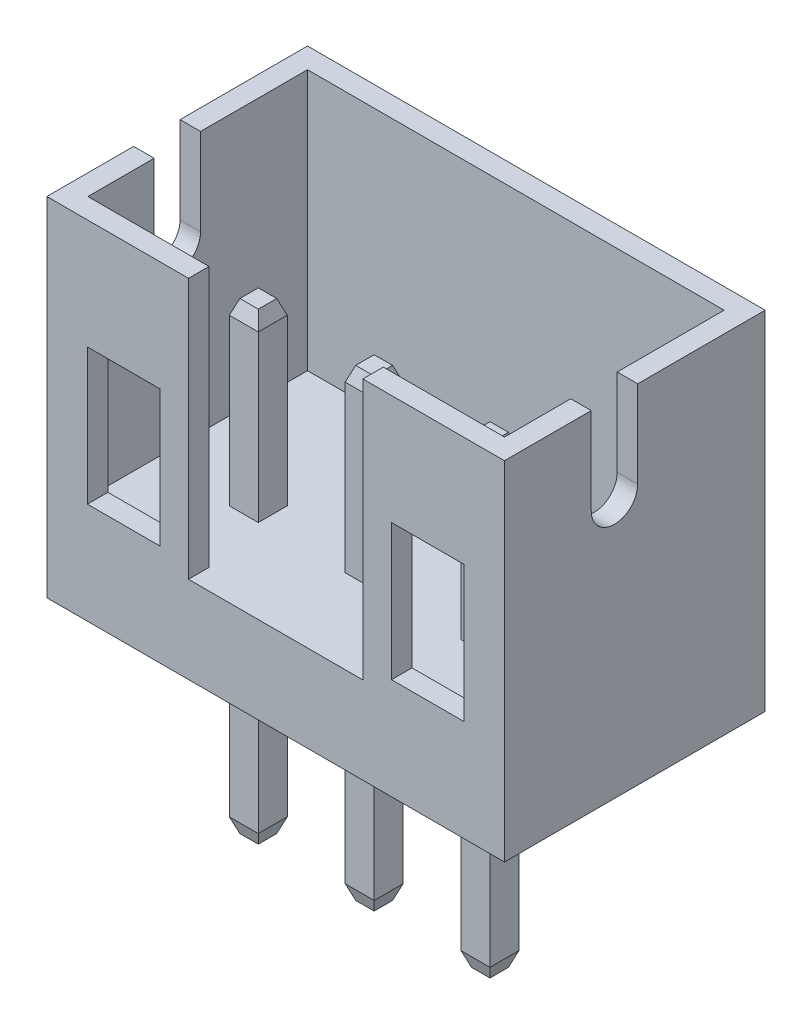
from build123d import *

# Parameters (mm, degrees)
SKETCH1_W              = 7.9
SKETCH1_H              = 6
BOSS_EXTRUDE1_DEPTH    = 4.5
SKETCH2_W              = 7.192186002
SKETCH2_H              = 3.792186002
CUT_EXTRUDE1_DEPTH     = 4.5
SKETCH3_W              = 1.504949596
SKETCH3_H              = 0.354260607
CUT_EXTRUDE2_DEPTH     = 4.5
CUT_EXTRUDE3_DEPTH     = 0.5
SKETCH6_W              = 1.25
SKETCH6_H              = 2.35
CUT_EXTRUDE4_DEPTH     = 0.5
BOSS_EXTRUDE3_START    = -3.4
SKETCH10_W             = 0.5
SKETCH10_H             = 0.5
BOSS_EXTRUDE3_DEPTH    = 8
CHAMFER1_SIZE          = 0.25
CHAMFER1_SIZE2         = 0.090992559
CHAMFER1_PART_2_SIZE   = 0.25
CHAMFER1_PART_2_SIZE2  = 0.090992559
CHAMFER1_PART_3_SIZE   = 0.25
CHAMFER1_PART_3_SIZE2  = 0.090992559
CHAMFER1_PART_4_SIZE   = 0.25
CHAMFER1_PART_4_SIZE2  = 0.090992559
CHAMFER1_PART_5_SIZE   = 0.25
CHAMFER1_PART_5_SIZE2  = 0.090992559
CHAMFER1_PART_6_SIZE   = 0.25
CHAMFER1_PART_6_SIZE2  = 0.090992559
CHAMFER1_PART_7_SIZE   = 0.25
CHAMFER1_PART_7_SIZE2  = 0.090992559
CHAMFER1_PART_8_SIZE   = 0.25
CHAMFER1_PART_8_SIZE2  = 0.090992559
CHAMFER1_PART_9_SIZE   = 0.25
CHAMFER1_PART_9_SIZE2  = 0.090992559
CHAMFER1_PART_10_SIZE  = 0.25
CHAMFER1_PART_10_SIZE2 = 0.090992559
CHAMFER1_PART_11_SIZE  = 0.25
CHAMFER1_PART_11_SIZE2 = 0.090992559
CHAMFER1_PART_12_SIZE  = 0.25
CHAMFER1_PART_12_SIZE2 = 0.090992559
CHAMFER2_SIZE          = 0.25
CHAMFER2_SIZE2         = 0.090992559
CHAMFER2_PART_2_SIZE   = 0.25
CHAMFER2_PART_2_SIZE2  = 0.090992559
CHAMFER2_PART_3_SIZE   = 0.25
CHAMFER2_PART_3_SIZE2  = 0.090992559
CHAMFER2_PART_4_SIZE   = 0.25
CHAMFER2_PART_4_SIZE2  = 0.090992559
CHAMFER2_PART_5_SIZE   = 0.25
CHAMFER2_PART_5_SIZE2  = 0.090992559
CHAMFER2_PART_6_SIZE   = 0.25
CHAMFER2_PART_6_SIZE2  = 0.090992559
CHAMFER2_PART_7_SIZE   = 0.25
CHAMFER2_PART_7_SIZE2  = 0.090992559
CHAMFER2_PART_8_SIZE   = 0.25
CHAMFER2_PART_8_SIZE2  = 0.090992559
CHAMFER2_PART_9_SIZE   = 0.25
CHAMFER2_PART_9_SIZE2  = 0.090992559
CHAMFER2_PART_10_SIZE  = 0.25
CHAMFER2_PART_10_SIZE2 = 0.090992559
CHAMFER2_PART_11_SIZE  = 0.25
CHAMFER2_PART_11_SIZE2 = 0.090992559
CHAMFER2_PART_12_SIZE  = 0.25
CHAMFER2_PART_12_SIZE2 = 0.090992559


with BuildPart() as part:
    # Sketch1 → Boss-Extrude1 (new body)
    with BuildSketch(Plane.XY):
        with Locations((3.95, 3)):
            Rectangle(SKETCH1_W, SKETCH1_H)
    extrude(amount=-BOSS_EXTRUDE1_DEPTH)

    # Sketch2 → Cut-Extrude1 (cut)
    with BuildSketch(Plane(origin=(0, 6, 0), x_dir=(1, 0, 0), z_dir=(0, 1, 0))):
        with Locations((3.950353608, 2.249646392)):
            Rectangle(SKETCH2_W, SKETCH2_H)
    extrude(amount=-CUT_EXTRUDE1_DEPTH, mode=Mode.SUBTRACT)

    # Sketch3 → Cut-Extrude2 (cut)
    with BuildSketch(Plane(origin=(0, 1.5, 0), x_dir=(1, 0, 0), z_dir=(0, 1, 0))):
        with Locations((3.197525202, 0.177130304)):
            Rectangle(SKETCH3_W, SKETCH3_H)
    cut_extrude2 = extrude(amount=CUT_EXTRUDE2_DEPTH, mode=Mode.SUBTRACT)

    # Sketch5 → Cut-Extrude3 (cut)
    with BuildSketch(Plane(origin=(7.9, 0, 0), x_dir=(0, 0, -1), z_dir=(1, 0, 0))):
        with BuildLine():
            Line((2.299478677, 6), (1.497924103, 6))
            Line((1.497924103, 6), (1.497924103, 4.5))
            ThreePointArc((1.497924103, 4.5), (1.89870139, 4.900777287), (2.299478677, 4.5))
            Line((2.299478677, 4.5), (2.299478677, 6))
        make_face()
        with BuildLine():
            ThreePointArc((2.299478677, 4.5), (1.89870139, 4.900777287), (1.497924103, 4.5))
            Line((1.497924103, 4.5), (2.299478677, 4.5))
        make_face()
        with BuildLine():
            Line((2.299478677, 4.5), (1.497924103, 4.5))
            ThreePointArc((1.497924103, 4.5), (1.89870139, 4.099222713), (2.299478677, 4.5))
        make_face()
    cut_extrude3 = extrude(amount=-CUT_EXTRUDE3_DEPTH, mode=Mode.SUBTRACT)

    # Mirror1: Cut-Extrude3 across plane
    add(cut_extrude3.mirror(Plane(origin=(3.95, 0, 0), x_dir=(0, 0, 1), z_dir=(1, 0, 0))), mode=Mode.SUBTRACT)

    # Sketch6 → Cut-Extrude4 (cut)
    with BuildSketch(Plane.XY):
        with Locations((1.325196701, 2.925654718)):
            Rectangle(SKETCH6_W, SKETCH6_H)
    cut_extrude4 = extrude(amount=-CUT_EXTRUDE4_DEPTH, mode=Mode.SUBTRACT)

    # Sketch10 → Boss-Extrude3 (add)
    with BuildSketch(Plane(origin=(0, 0, 0), x_dir=(1, 0, 0), z_dir=(0, 1, 0)).offset(BOSS_EXTRUDE3_START)):
        with Locations((1.95, 1.7)):
            Rectangle(SKETCH10_W, SKETCH10_H)
        with Locations((3.95, 1.7)):
            Rectangle(SKETCH10_W, SKETCH10_H)
        with Locations((5.95, 1.7)):
            Rectangle(SKETCH10_W, SKETCH10_H)
    extrude(amount=BOSS_EXTRUDE3_DEPTH)

    # Chamfer1
    chamfer1_edges = [part.edges().sort_by_distance(p)[0] for p in [
        (2.2, 4.6, -1.7),
    ]]
    chamfer1_side = [part.faces().sort_by_distance(p)[0] for p in [
        (2.2, 3.05, -1.7),
    ]]
    chamfer(chamfer1_edges, length=CHAMFER1_SIZE, length2=CHAMFER1_SIZE2, reference=chamfer1_side[0])

    # Chamfer1 part 2
    chamfer1_part_2_edges = [part.edges().sort_by_distance(p)[0] for p in [
        (1.95, 4.6, -1.95),
    ]]
    chamfer1_part_2_side = [part.faces().sort_by_distance(p)[0] for p in [
        (1.95, 3.05, -1.95),
    ]]
    chamfer(chamfer1_part_2_edges, length=CHAMFER1_PART_2_SIZE, length2=CHAMFER1_PART_2_SIZE2, reference=chamfer1_part_2_side[0])

    # Chamfer1 part 3
    chamfer1_part_3_edges = [part.edges().sort_by_distance(p)[0] for p in [
        (1.7, 4.6, -1.7),
    ]]
    chamfer1_part_3_side = [part.faces().sort_by_distance(p)[0] for p in [
        (1.7, 3.05, -1.7),
    ]]
    chamfer(chamfer1_part_3_edges, length=CHAMFER1_PART_3_SIZE, length2=CHAMFER1_PART_3_SIZE2, reference=chamfer1_part_3_side[0])

    # Chamfer1 part 4
    chamfer1_part_4_edges = [part.edges().sort_by_distance(p)[0] for p in [
        (1.95, 4.6, -1.45),
    ]]
    chamfer1_part_4_side = [part.faces().sort_by_distance(p)[0] for p in [
        (1.95, 3.05, -1.45),
    ]]
    chamfer(chamfer1_part_4_edges, length=CHAMFER1_PART_4_SIZE, length2=CHAMFER1_PART_4_SIZE2, reference=chamfer1_part_4_side[0])

    # Chamfer1 part 5
    chamfer1_part_5_edges = [part.edges().sort_by_distance(p)[0] for p in [
        (4.2, 4.6, -1.7),
    ]]
    chamfer1_part_5_side = [part.faces().sort_by_distance(p)[0] for p in [
        (4.2, 3.05, -1.7),
    ]]
    chamfer(chamfer1_part_5_edges, length=CHAMFER1_PART_5_SIZE, length2=CHAMFER1_PART_5_SIZE2, reference=chamfer1_part_5_side[0])

    # Chamfer1 part 6
    chamfer1_part_6_edges = [part.edges().sort_by_distance(p)[0] for p in [
        (3.95, 4.6, -1.95),
    ]]
    chamfer1_part_6_side = [part.faces().sort_by_distance(p)[0] for p in [
        (3.95, 3.05, -1.95),
    ]]
    chamfer(chamfer1_part_6_edges, length=CHAMFER1_PART_6_SIZE, length2=CHAMFER1_PART_6_SIZE2, reference=chamfer1_part_6_side[0])

    # Chamfer1 part 7
    chamfer1_part_7_edges = [part.edges().sort_by_distance(p)[0] for p in [
        (3.7, 4.6, -1.7),
    ]]
    chamfer1_part_7_side = [part.faces().sort_by_distance(p)[0] for p in [
        (3.7, 3.05, -1.7),
    ]]
    chamfer(chamfer1_part_7_edges, length=CHAMFER1_PART_7_SIZE, length2=CHAMFER1_PART_7_SIZE2, reference=chamfer1_part_7_side[0])

    # Chamfer1 part 8
    chamfer1_part_8_edges = [part.edges().sort_by_distance(p)[0] for p in [
        (3.95, 4.6, -1.45),
    ]]
    chamfer1_part_8_side = [part.faces().sort_by_distance(p)[0] for p in [
        (3.95, 3.05, -1.45),
    ]]
    chamfer(chamfer1_part_8_edges, length=CHAMFER1_PART_8_SIZE, length2=CHAMFER1_PART_8_SIZE2, reference=chamfer1_part_8_side[0])

    # Chamfer1 part 9
    chamfer1_part_9_edges = [part.edges().sort_by_distance(p)[0] for p in [
        (6.2, 4.6, -1.7),
    ]]
    chamfer1_part_9_side = [part.faces().sort_by_distance(p)[0] for p in [
        (6.2, 3.05, -1.7),
    ]]
    chamfer(chamfer1_part_9_edges, length=CHAMFER1_PART_9_SIZE, length2=CHAMFER1_PART_9_SIZE2, reference=chamfer1_part_9_side[0])

    # Chamfer1 part 10
    chamfer1_part_10_edges = [part.edges().sort_by_distance(p)[0] for p in [
        (5.95, 4.6, -1.95),
    ]]
    chamfer1_part_10_side = [part.faces().sort_by_distance(p)[0] for p in [
        (5.95, 3.05, -1.95),
    ]]
    chamfer(chamfer1_part_10_edges, length=CHAMFER1_PART_10_SIZE, length2=CHAMFER1_PART_10_SIZE2, reference=chamfer1_part_10_side[0])

    # Chamfer1 part 11
    chamfer1_part_11_edges = [part.edges().sort_by_distance(p)[0] for p in [
        (5.7, 4.6, -1.7),
    ]]
    chamfer1_part_11_side = [part.faces().sort_by_distance(p)[0] for p in [
        (5.7, 3.05, -1.7),
    ]]
    chamfer(chamfer1_part_11_edges, length=CHAMFER1_PART_11_SIZE, length2=CHAMFER1_PART_11_SIZE2, reference=chamfer1_part_11_side[0])

    # Chamfer1 part 12
    chamfer1_part_12_edges = [part.edges().sort_by_distance(p)[0] for p in [
        (5.95, 4.6, -1.45),
    ]]
    chamfer1_part_12_side = [part.faces().sort_by_distance(p)[0] for p in [
        (5.95, 3.05, -1.45),
    ]]
    chamfer(chamfer1_part_12_edges, length=CHAMFER1_PART_12_SIZE, length2=CHAMFER1_PART_12_SIZE2, reference=chamfer1_part_12_side[0])

    # Chamfer2
    chamfer2_edges = [part.edges().sort_by_distance(p)[0] for p in [
        (2.2, -3.4, -1.7),
    ]]
    chamfer2_side = [part.faces().sort_by_distance(p)[0] for p in [
        (2.2, -1.7, -1.7),
    ]]
    chamfer(chamfer2_edges, length=CHAMFER2_SIZE, length2=CHAMFER2_SIZE2, reference=chamfer2_side[0])

    # Chamfer2 part 2
    chamfer2_part_2_edges = [part.edges().sort_by_distance(p)[0] for p in [
        (1.95, -3.4, -1.95),
    ]]
    chamfer2_part_2_side = [part.faces().sort_by_distance(p)[0] for p in [
        (1.95, -1.7, -1.95),
    ]]
    chamfer(chamfer2_part_2_edges, length=CHAMFER2_PART_2_SIZE, length2=CHAMFER2_PART_2_SIZE2, reference=chamfer2_part_2_side[0])

    # Chamfer2 part 3
    chamfer2_part_3_edges = [part.edges().sort_by_distance(p)[0] for p in [
        (1.7, -3.4, -1.7),
    ]]
    chamfer2_part_3_side = [part.faces().sort_by_distance(p)[0] for p in [
        (1.7, -1.7, -1.7),
    ]]
    chamfer(chamfer2_part_3_edges, length=CHAMFER2_PART_3_SIZE, length2=CHAMFER2_PART_3_SIZE2, reference=chamfer2_part_3_side[0])

    # Chamfer2 part 4
    chamfer2_part_4_edges = [part.edges().sort_by_distance(p)[0] for p in [
        (1.95, -3.4, -1.45),
    ]]
    chamfer2_part_4_side = [part.faces().sort_by_distance(p)[0] for p in [
        (1.95, -1.7, -1.45),
    ]]
    chamfer(chamfer2_part_4_edges, length=CHAMFER2_PART_4_SIZE, length2=CHAMFER2_PART_4_SIZE2, reference=chamfer2_part_4_side[0])

    # Chamfer2 part 5
    chamfer2_part_5_edges = [part.edges().sort_by_distance(p)[0] for p in [
        (4.2, -3.4, -1.7),
    ]]
    chamfer2_part_5_side = [part.faces().sort_by_distance(p)[0] for p in [
        (4.2, -1.7, -1.7),
    ]]
    chamfer(chamfer2_part_5_edges, length=CHAMFER2_PART_5_SIZE, length2=CHAMFER2_PART_5_SIZE2, reference=chamfer2_part_5_side[0])

    # Chamfer2 part 6
    chamfer2_part_6_edges = [part.edges().sort_by_distance(p)[0] for p in [
        (3.95, -3.4, -1.95),
    ]]
    chamfer2_part_6_side = [part.faces().sort_by_distance(p)[0] for p in [
        (3.95, -1.7, -1.95),
    ]]
    chamfer(chamfer2_part_6_edges, length=CHAMFER2_PART_6_SIZE, length2=CHAMFER2_PART_6_SIZE2, reference=chamfer2_part_6_side[0])

    # Chamfer2 part 7
    chamfer2_part_7_edges = [part.edges().sort_by_distance(p)[0] for p in [
        (3.7, -3.4, -1.7),
    ]]
    chamfer2_part_7_side = [part.faces().sort_by_distance(p)[0] for p in [
        (3.7, -1.7, -1.7),
    ]]
    chamfer(chamfer2_part_7_edges, length=CHAMFER2_PART_7_SIZE, length2=CHAMFER2_PART_7_SIZE2, reference=chamfer2_part_7_side[0])

    # Chamfer2 part 8
    chamfer2_part_8_edges = [part.edges().sort_by_distance(p)[0] for p in [
        (3.95, -3.4, -1.45),
    ]]
    chamfer2_part_8_side = [part.faces().sort_by_distance(p)[0] for p in [
        (3.95, -1.7, -1.45),
    ]]
    chamfer(chamfer2_part_8_edges, length=CHAMFER2_PART_8_SIZE, length2=CHAMFER2_PART_8_SIZE2, reference=chamfer2_part_8_side[0])

    # Chamfer2 part 9
    chamfer2_part_9_edges = [part.edges().sort_by_distance(p)[0] for p in [
        (6.2, -3.4, -1.7),
    ]]
    chamfer2_part_9_side = [part.faces().sort_by_distance(p)[0] for p in [
        (6.2, -1.7, -1.7),
    ]]
    chamfer(chamfer2_part_9_edges, length=CHAMFER2_PART_9_SIZE, length2=CHAMFER2_PART_9_SIZE2, reference=chamfer2_part_9_side[0])

    # Chamfer2 part 10
    chamfer2_part_10_edges = [part.edges().sort_by_distance(p)[0] for p in [
        (5.95, -3.4, -1.95),
    ]]
    chamfer2_part_10_side = [part.faces().sort_by_distance(p)[0] for p in [
        (5.95, -1.7, -1.95),
    ]]
    chamfer(chamfer2_part_10_edges, length=CHAMFER2_PART_10_SIZE, length2=CHAMFER2_PART_10_SIZE2, reference=chamfer2_part_10_side[0])

    # Chamfer2 part 11
    chamfer2_part_11_edges = [part.edges().sort_by_distance(p)[0] for p in [
        (5.7, -3.4, -1.7),
    ]]
    chamfer2_part_11_side = [part.faces().sort_by_distance(p)[0] for p in [
        (5.7, -1.7, -1.7),
    ]]
    chamfer(chamfer2_part_11_edges, length=CHAMFER2_PART_11_SIZE, length2=CHAMFER2_PART_11_SIZE2, reference=chamfer2_part_11_side[0])

    # Chamfer2 part 12
    chamfer2_part_12_edges = [part.edges().sort_by_distance(p)[0] for p in [
        (5.95, -3.4, -1.45),
    ]]
    chamfer2_part_12_side = [part.faces().sort_by_distance(p)[0] for p in [
        (5.95, -1.7, -1.45),
    ]]
    chamfer(chamfer2_part_12_edges, length=CHAMFER2_PART_12_SIZE, length2=CHAMFER2_PART_12_SIZE2, reference=chamfer2_part_12_side[0])

    # Mirror2: Cut-Extrude2, Cut-Extrude4 across plane
    add(cut_extrude2.mirror(Plane(origin=(3.95, 0, 0), x_dir=(0, 0, 1), z_dir=(1, 0, 0))), mode=Mode.SUBTRACT)
    add(cut_extrude4.mirror(Plane(origin=(3.95, 0, 0), x_dir=(0, 0, 1), z_dir=(1, 0, 0))), mode=Mode.SUBTRACT)


solid = part.part
